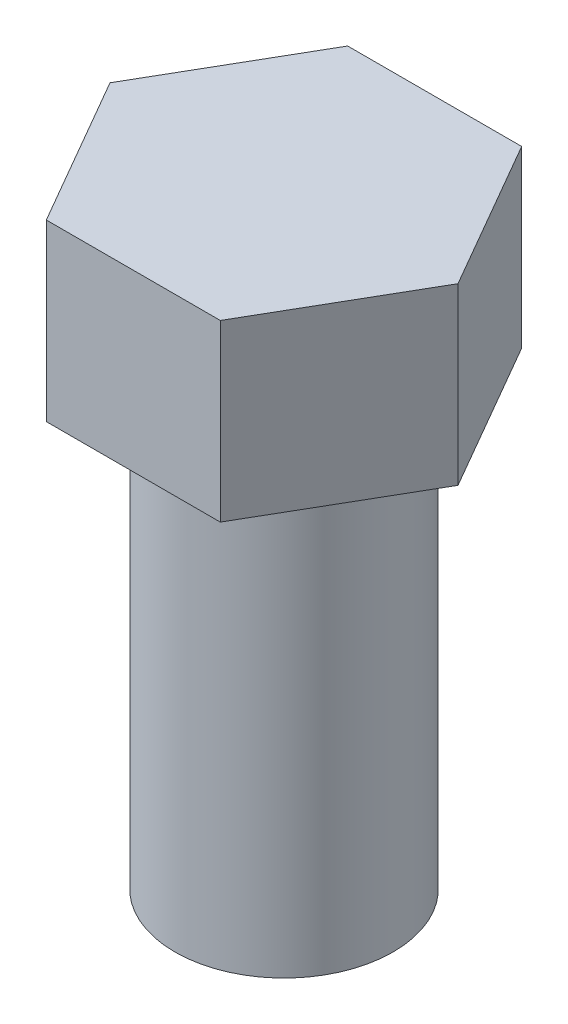
from build123d import *

# Parameters (mm, degrees)
SKETCH1_R           = 63.5
BOSS_EXTRUDE1_DEPTH = 254
BOSS_EXTRUDE2_DEPTH = 101.6


with BuildPart() as part:
    # Sketch1 → Boss-Extrude1 (new body)
    with BuildSketch(Plane(origin=(0, 0, 0), x_dir=(1, 0, 0), z_dir=(0, 1, 0))):
        Circle(SKETCH1_R)
    extrude(amount=-BOSS_EXTRUDE1_DEPTH)

    # Sketch2 → Boss-Extrude2 (add)
    with BuildSketch(Plane(origin=(0, 0, 0), x_dir=(1, 0, 0), z_dir=(0, 1, 0))):
        Polygon((-50.613670356, 87.665448614), (50.613670356, 87.665448614), (101.227340712, 0), (50.613670356, -87.665448614), (-50.613670356, -87.665448614), (-101.227340712, 0), align=None)
    extrude(amount=BOSS_EXTRUDE2_DEPTH)


solid = part.part
